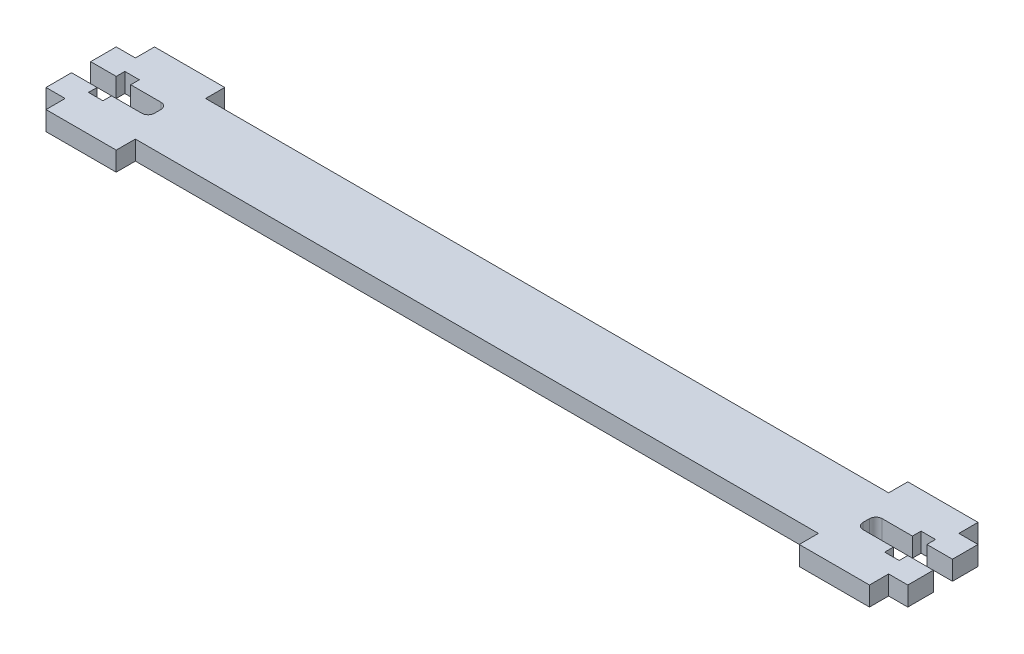
from build123d import *

# Parameters (mm, degrees)
SKETCH1_W               = 107
SKETCH1_H               = 11
BOSS_EXTRUDE1_DEPTH     = 1.5
SKETCH3_W               = 11
SKETCH3_H               = 17
BOSS_EXTRUDE2_DEPTH     = 1.5
SKETCH4_W               = 3
SKETCH4_H               = 11
BOSS_EXTRUDE3_DEPTH     = 1.5
CUT_EXTRUDE1_DEPTH      = 69.049614253
CUT_EXTRUDE1_DEPTH_BACK = 69.049614253


with BuildPart() as part:
    # Sketch1 → Boss-Extrude1 (new, symmetric)
    with BuildSketch(Plane(origin=(0, 0, 0), x_dir=(1, 0, 0), z_dir=(0, 1, 0))):
        Rectangle(SKETCH1_W, SKETCH1_H)
    extrude(amount=BOSS_EXTRUDE1_DEPTH, both=True)

    # Sketch3 → Boss-Extrude2 (add, symmetric)
    with BuildSketch(Plane(origin=(0, 0, 0), x_dir=(1, 0, 0), z_dir=(0, 1, 0))):
        with Locations((-59, 0)):
            Rectangle(SKETCH3_W, SKETCH3_H)
        with Locations((59, 0)):
            Rectangle(SKETCH3_W, SKETCH3_H)
    extrude(amount=BOSS_EXTRUDE2_DEPTH, both=True)

    # Sketch4 → Boss-Extrude3 (add, symmetric)
    with BuildSketch(Plane(origin=(0, 0, 0), x_dir=(1, 0, 0), z_dir=(0, 1, 0))):
        with Locations((-66, 0)):
            Rectangle(SKETCH4_W, SKETCH4_H)
        with Locations((66, 0)):
            Rectangle(SKETCH4_W, SKETCH4_H)
    extrude(amount=BOSS_EXTRUDE3_DEPTH, both=True)

    # Sketch2 → Cut-Extrude1 (cut, two sides)
    with BuildSketch(Plane(origin=(0, 0, 0), x_dir=(1, 0, 0), z_dir=(0, 1, 0))) as cut_extrude1_sk:
        with BuildLine():
            Line((-67.5, 1.5), (-63.5, 1.5))
            Line((-63.5, 1.5), (-63.5, 2.85))
            Line((-63.5, 2.85), (-61.23, 2.85))
            Line((-61.23, 2.85), (-61.23, 1.5))
            Line((-61.23, 1.5), (-56.5, 1.5))
            ThreePointArc((-56.5, 1.5), (-55.792893219, 1.207106781), (-55.5, 0.5))
            Line((-55.5, 0.5), (-55.5, -0.5))
            ThreePointArc((-55.5, -0.5), (-55.792893219, -1.207106781), (-56.5, -1.5))
            Line((-56.5, -1.5), (-61.23, -1.5))
            Line((-61.23, -1.5), (-61.23, -2.85))
            Line((-61.23, -2.85), (-63.5, -2.85))
            Line((-63.5, -2.85), (-63.5, -1.5))
            Line((-63.5, -1.5), (-67.5, -1.5))
            Line((-67.5, -1.5), (-67.5, 1.5))
        make_face()
        with BuildLine():
            Line((61.23, -1.5), (56.5, -1.5))
            ThreePointArc((56.5, -1.5), (55.792893219, -1.207106781), (55.5, -0.5))
            Line((55.5, -0.5), (55.5, 0.5))
            ThreePointArc((55.5, 0.5), (55.792893219, 1.207106781), (56.5, 1.5))
            Line((56.5, 1.5), (61.23, 1.5))
            Line((61.23, 1.5), (61.23, 2.85))
            Line((61.23, 2.85), (63.5, 2.85))
            Line((63.5, 2.85), (63.5, 1.5))
            Line((63.5, 1.5), (67.5, 1.5))
            Line((67.5, 1.5), (67.5, -1.5))
            Line((67.5, -1.5), (63.5, -1.5))
            Line((63.5, -1.5), (63.5, -2.85))
            Line((63.5, -2.85), (61.23, -2.85))
            Line((61.23, -2.85), (61.23, -1.5))
        make_face()
    extrude(amount=CUT_EXTRUDE1_DEPTH, mode=Mode.SUBTRACT)
    extrude(cut_extrude1_sk.sketch, amount=-CUT_EXTRUDE1_DEPTH_BACK, mode=Mode.SUBTRACT)


solid = part.part
